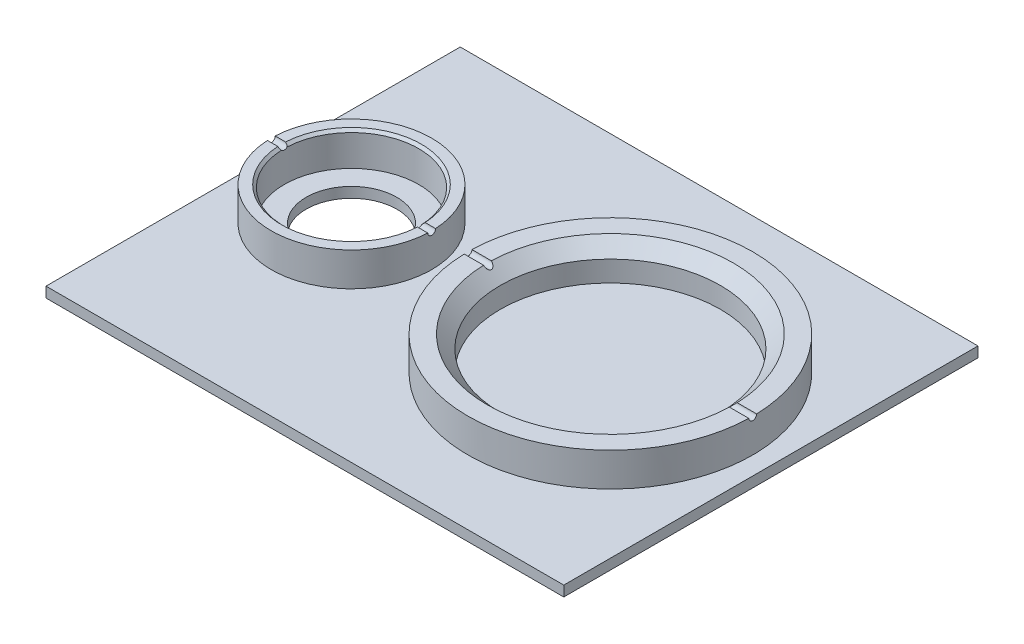
from build123d import *

# Parameters (mm, degrees)
SKETCH1_W                = 200
SKETCH1_H                = 160
BOSS_EXTRUDE1_DEPTH      = 4
SKETCH2_R                = 31
SKETCH2_R_2              = 26
SKETCH2_R_3              = 55
SKETCH2_R_4              = 42.5
BOSS_EXTRUDE2_DEPTH      = 13
CHAMFER2_SIZE            = 5
CHAMFER4_SIZE            = 1
SKETCH9_R                = 17.5
CUT_EXTRUDE8_DEPTH       = 5
SKETCH11_R               = 1.5
CUT_EXTRUDE10_DEPTH      = 101
CUT_EXTRUDE10_DEPTH_BACK = 101


with BuildPart() as part:
    # Sketch1 → Boss-Extrude1 (new body)
    with BuildSketch(Plane(origin=(0, 0, 0), x_dir=(1, 0, 0), z_dir=(0, 1, 0))):
        Rectangle(SKETCH1_W, SKETCH1_H)
    extrude(amount=BOSS_EXTRUDE1_DEPTH)

    # Sketch2 → Boss-Extrude2 (add)
    with BuildSketch(Plane(origin=(0, 4, 0), x_dir=(1, 0, 0), z_dir=(0, 1, 0))):
        with Locations((-62, 0)):
            Circle(SKETCH2_R)
        with Locations((-62, 0)):
            Circle(SKETCH2_R_2, mode=Mode.SUBTRACT)
        with Locations((38, 0)):
            Circle(SKETCH2_R_3)
        with Locations((38, 0)):
            Circle(SKETCH2_R_4, mode=Mode.SUBTRACT)
    extrude(amount=BOSS_EXTRUDE2_DEPTH)

    # Chamfer2
    chamfer2_edges = [part.edges().sort_by_distance(p)[0] for p in [
        (-4.5, 17, 0),
    ]]
    chamfer(chamfer2_edges, length=CHAMFER2_SIZE)

    # Chamfer4
    chamfer4_edges = [part.edges().sort_by_distance(p)[0] for p in [
        (-88, 17, 0),
    ]]
    chamfer(chamfer4_edges, length=CHAMFER4_SIZE)

    # Sketch9 → Cut-Extrude8 (cut, through all)
    with BuildSketch(Plane(origin=(0, 4, 0), x_dir=(1, 0, 0), z_dir=(0, 1, 0))):
        with Locations((-62, 0)):
            Circle(SKETCH9_R)
    extrude(amount=-CUT_EXTRUDE8_DEPTH, mode=Mode.SUBTRACT)

    # Sketch11 → Cut-Extrude10 (cut, two sides)
    with BuildSketch(Plane(origin=(0, 0, 0), x_dir=(0, 0, -1), z_dir=(1, 0, 0))) as cut_extrude10_sk:
        with Locations((0, 17)):
            Circle(SKETCH11_R)
    extrude(amount=CUT_EXTRUDE10_DEPTH, mode=Mode.SUBTRACT)
    extrude(cut_extrude10_sk.sketch, amount=-CUT_EXTRUDE10_DEPTH_BACK, mode=Mode.SUBTRACT)


solid = part.part
